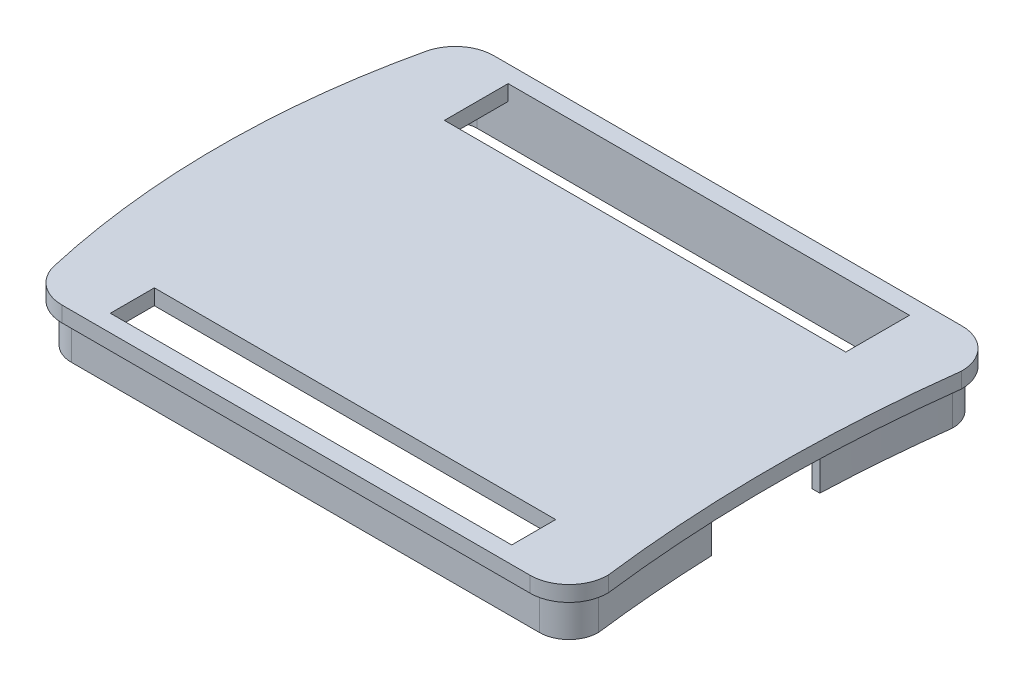
from build123d import *

# Parameters (mm, degrees)
BOSS_EXTRUDE1_DEPTH = 2
BOSS_EXTRUDE2_DEPTH = 5
SKETCH4_W           = 51.8
SKETCH4_H           = 8.22
SKETCH4_H_2         = 5.68
CUT_EXTRUDE1_DEPTH  = 2
BOSS_EXTRUDE3_DEPTH = 5
SKETCH8_W           = 5.977250124
SKETCH8_H           = 14
CUT_EXTRUDE3_DEPTH  = 4
SKETCH9_W           = 9.791789178
SKETCH9_H           = 32.4
CUT_EXTRUDE4_DEPTH  = 4


with BuildPart() as part:
    # Sketch2 → Boss-Extrude1 (new body)
    with BuildSketch(Plane(origin=(0, 0, 0), x_dir=(1, 0, 0), z_dir=(0, 1, 0))):
        with BuildLine():
            Line((-29.941284627, -27.87), (30.48, -27.87))
            ThreePointArc((30.48, -27.87), (34.050723427, -26.374261545), (35.489363684, -22.780153375))
            ThreePointArc((35.489363684, -22.780153375), (34.068, 0), (35.489363684, 22.780153375))
            ThreePointArc((35.489363684, 22.780153375), (34.050723427, 26.374261545), (30.48, 27.87))
            Line((30.48, 27.87), (-29.941284627, 27.87))
            ThreePointArc((-29.941284627, 27.87), (-33.058077828, 26.779680312), (-34.815550633, 23.984240056))
            ThreePointArc((-34.815550633, 23.984240056), (-37.522, 0), (-34.815550633, -23.984240056))
            ThreePointArc((-34.815550633, -23.984240056), (-33.058077828, -26.779680312), (-29.941284627, -27.87))
        make_face()
    extrude(amount=BOSS_EXTRUDE1_DEPTH)

    # Sketch3 → Boss-Extrude2 (add)
    with BuildSketch(Plane.XZ):
        with BuildLine():
            Line((-29.941284627, -26.67), (30.48, -26.67))
            ThreePointArc((30.48, -26.67), (33.174076836, -25.554076836), (34.29, -22.86))
            ThreePointArc((34.29, -22.86), (32.868, 0), (34.29, 22.86))
            ThreePointArc((34.29, 22.86), (33.174076836, 25.554076836), (30.48, 26.67))
            Line((30.48, 26.67), (-29.941284627, 26.67))
            ThreePointArc((-29.941284627, 26.67), (-32.31004746, 25.841357037), (-33.645726791, 23.716822443))
            ThreePointArc((-33.645726791, 23.716822443), (-36.322, 0), (-33.645726791, -23.716822443))
            ThreePointArc((-33.645726791, -23.716822443), (-32.31004746, -25.841357037), (-29.941284627, -26.67))
        make_face()
        with BuildLine():
            Line((30.48, 25.67), (-29.941284627, 25.67))
            ThreePointArc((-29.941284627, 25.67), (-31.686688819, 25.059420975), (-32.67087359, 23.493974431))
            ThreePointArc((-32.67087359, 23.493974431), (-35.322, 0), (-32.67087359, -23.493974431))
            ThreePointArc((-32.67087359, -23.493974431), (-31.686688819, -25.059420975), (-29.941284627, -25.67))
            Line((-29.941284627, -25.67), (30.48, -25.67))
            ThreePointArc((30.48, -25.67), (32.446567575, -24.867165158), (33.289413465, -22.917410657))
            ThreePointArc((33.289413465, -22.917410657), (31.868, 0), (33.289413465, 22.917410657))
            ThreePointArc((33.289413465, 22.917410657), (32.446567575, 24.867165158), (30.48, 25.67))
        make_face(mode=Mode.SUBTRACT)
    extrude(amount=BOSS_EXTRUDE2_DEPTH)

    # Sketch4 → Cut-Extrude1 (cut)
    with BuildSketch(Plane(origin=(0, 2, 0), x_dir=(1, 0, 0), z_dir=(0, 1, 0))):
        with Locations((-0.000636316, 21.56)):
            Rectangle(SKETCH4_W, SKETCH4_H)
        with Locations((-0.000636316, -22.83)):
            Rectangle(SKETCH4_W, SKETCH4_H_2)
    extrude(amount=-CUT_EXTRUDE1_DEPTH, mode=Mode.SUBTRACT)

    # Sketch6 → Boss-Extrude3 (add)
    with BuildSketch(Plane.XZ):
        with BuildLine():
            Line((-36.326051564, 16), (-34.100805436, 16))
            ThreePointArc((-34.100805436, 16), (-35.322, 0), (-34.100805436, -16))
            Line((-34.100805436, -16), (-36.326051564, -16))
            ThreePointArc((-36.326051564, -16), (-37.522, 0), (-36.326051564, 16))
        make_face()
    extrude(amount=BOSS_EXTRUDE3_DEPTH)

    # Sketch8 → Cut-Extrude3 (cut)
    with BuildSketch(Plane.XZ.offset(5)):
        with Locations((32.449466872, 0)):
            Rectangle(SKETCH8_W, SKETCH8_H)
    extrude(amount=-CUT_EXTRUDE3_DEPTH, mode=Mode.SUBTRACT)

    # Sketch9 → Cut-Extrude4 (cut)
    with BuildSketch(Plane(origin=(0, -5, 0), x_dir=(-1, 0, 0), z_dir=(0, -1, 0))):
        with Locations((35.349982691, 0)):
            Rectangle(SKETCH9_W, SKETCH9_H)
    extrude(amount=-CUT_EXTRUDE4_DEPTH, mode=Mode.SUBTRACT)


solid = part.part
